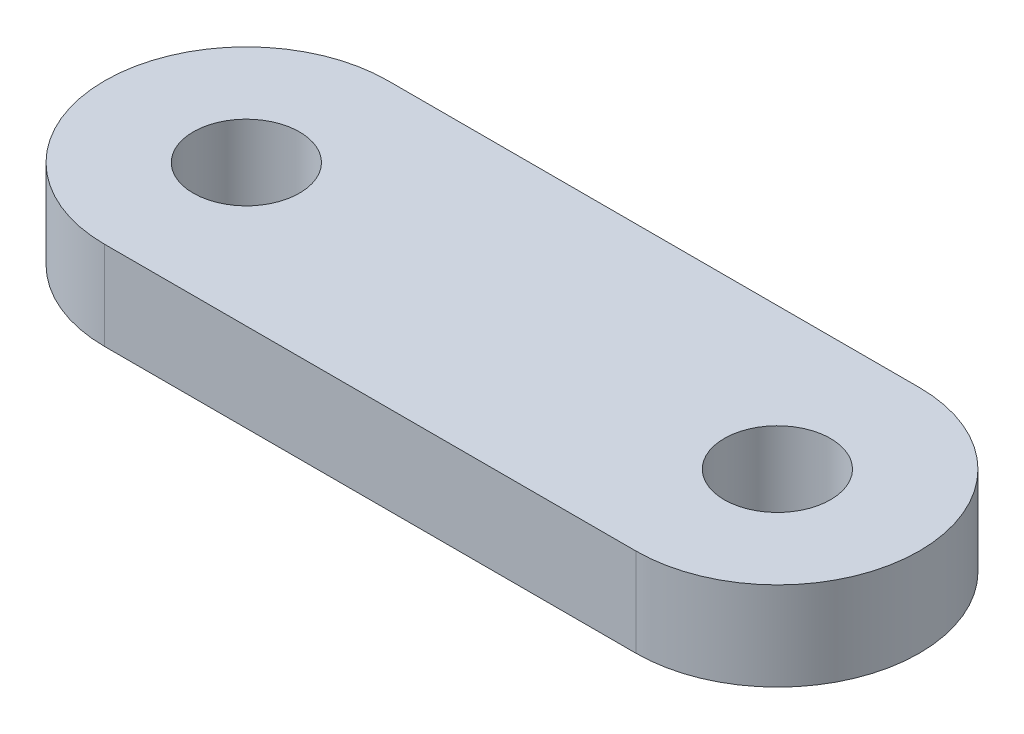
from build123d import *

# Parameters (mm, degrees)
BOSS_EXTRUDE1_DEPTH = 2.5
SKETCH2_R           = 1.5
CUT_EXTRUDE1_DEPTH  = 2.5


with BuildPart() as part:
    # Sketch1 → Boss-Extrude1 (new body)
    with BuildSketch(Plane(origin=(0, 0, 0), x_dir=(1, 0, 0), z_dir=(0, 1, 0))):
        with BuildLine():
            Line((0, 4), (15, 4))
            ThreePointArc((15, 4), (19, 0), (15, -4))
            Line((15, -4), (0, -4))
            ThreePointArc((0, -4), (-4, 0), (0, 4))
        make_face()
    extrude(amount=BOSS_EXTRUDE1_DEPTH)

    # Sketch2 → Cut-Extrude1 (cut)
    with BuildSketch(Plane(origin=(0, 2.5, 0), x_dir=(1, 0, 0), z_dir=(0, 1, 0))):
        Circle(SKETCH2_R)
        with Locations((14.993133743, 0)):
            Circle(SKETCH2_R)
    extrude(amount=-CUT_EXTRUDE1_DEPTH, mode=Mode.SUBTRACT)


solid = part.part
